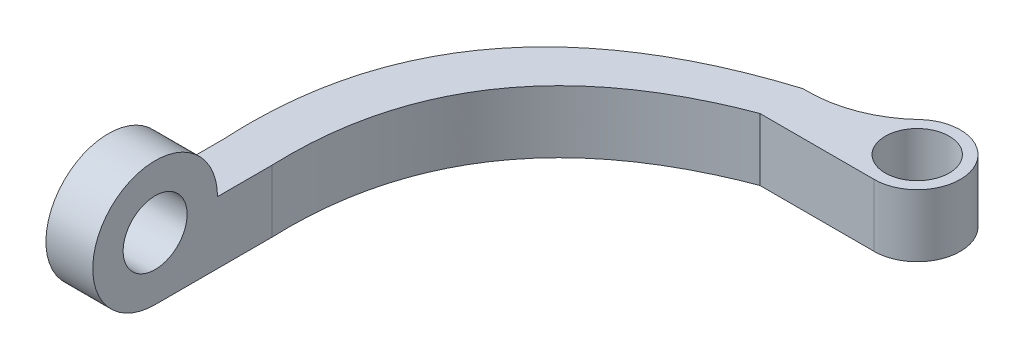
from build123d import *

# Parameters (mm, degrees)
RESSALTO_EXTRUS_O4_DEPTH = 8
ESBO_O7_R                = 4.1
CORTE_EXTRUS_O3_DEPTH    = 8
ESBO_O8_R                = 8
ESBO_O8_R_2              = 4.1
RESSALTO_EXTRUS_O5_DEPTH = 6
ESBO_O14_R               = 5.515467334
ESBO_O14_R_2             = 4.1
RESSALTO_EXTRUS_O8_DEPTH = 8
FILETE3_R                = 15
CORTE_EXTRUS_O6_DEPTH    = 8


with BuildPart() as part:
    # Esboço1 → Ressalto-extrusão4 (new body)
    with BuildSketch(Plane(origin=(0, 0, 0), x_dir=(1, 0, 0), z_dir=(0, 1, 0))):
        with BuildLine():
            Line((-8.455093814, 52.012944842), (6.19830879, 52.012944842))
            Line((6.19830879, 52.012944842), (6.19830879, 57.528412176))
            Line((6.19830879, 57.528412176), (-8.455093814, 57.528412176))
            add(Edge.make_bspline(
                [(-40, 15), (-41.806500993, 47.170631402), (-8.455093814, 57.528412176)],
                knots=[0, 0, 0, 1, 1, 1], degree=2))
            Line((-40, 15), (-40, 0))
            Line((-40, 0), (-34, 0))
            Line((-34, 0), (-34, 15))
            add(Edge.make_bspline(
                [(-34, 15), (-35.042952492, 42.040177947), (-8.455093814, 52.012944842)],
                knots=[0, 0, 0, 1, 1, 1], degree=2))
        make_face()
    extrude(amount=RESSALTO_EXTRUS_O4_DEPTH)

    # Esboço7 → Corte-extrusão3 (cut)
    with BuildSketch(Plane(origin=(-34, 0, 0), x_dir=(0, 0, -1), z_dir=(1, 0, 0))):
        with Locations((0, 8)):
            Circle(ESBO_O7_R)
    extrude(amount=-CORTE_EXTRUS_O3_DEPTH, mode=Mode.SUBTRACT)

    # Esboço8 → Ressalto-extrusão5 (add)
    with BuildSketch(Plane(origin=(-34, 0, 0), x_dir=(0, 0, -1), z_dir=(1, 0, 0))):
        with Locations((0, 8)):
            Circle(ESBO_O8_R)
        with Locations((0, 8)):
            Circle(ESBO_O8_R_2, mode=Mode.SUBTRACT)
    extrude(amount=-RESSALTO_EXTRUS_O5_DEPTH)

    # Esboço14 → Ressalto-extrusão8 (add)
    with BuildSketch(Plane(origin=(0, 8, 0), x_dir=(1, 0, 0), z_dir=(0, 1, 0))):
        with Locations((6.19830879, 57.528412176)):
            Circle(ESBO_O14_R)
        with Locations((6.19830879, 57.528412176)):
            Circle(ESBO_O14_R_2, mode=Mode.SUBTRACT)
    extrude(amount=-RESSALTO_EXTRUS_O8_DEPTH)

    # Filete3
    filete3_edges = [part.edges().sort_by_distance(p)[0] for p in [
        (0.682841456, 4, -57.528412176),
    ]]
    fillet(filete3_edges, radius=FILETE3_R)

    # Esboço15 → Corte-extrusão6 (cut)
    with BuildSketch(Plane(origin=(0, 8, 0), x_dir=(1, 0, 0), z_dir=(0, 1, 0))):
        with BuildLine():
            Line((6.19830879, 57.528412176), (2.09830879, 57.528412176))
            ThreePointArc((2.09830879, 57.528412176), (3.299170987, 54.629274373), (6.19830879, 53.428412176))
            Line((6.19830879, 53.428412176), (6.19830879, 57.528412176))
        make_face()
    extrude(amount=-CORTE_EXTRUS_O6_DEPTH, mode=Mode.SUBTRACT)


solid = part.part
